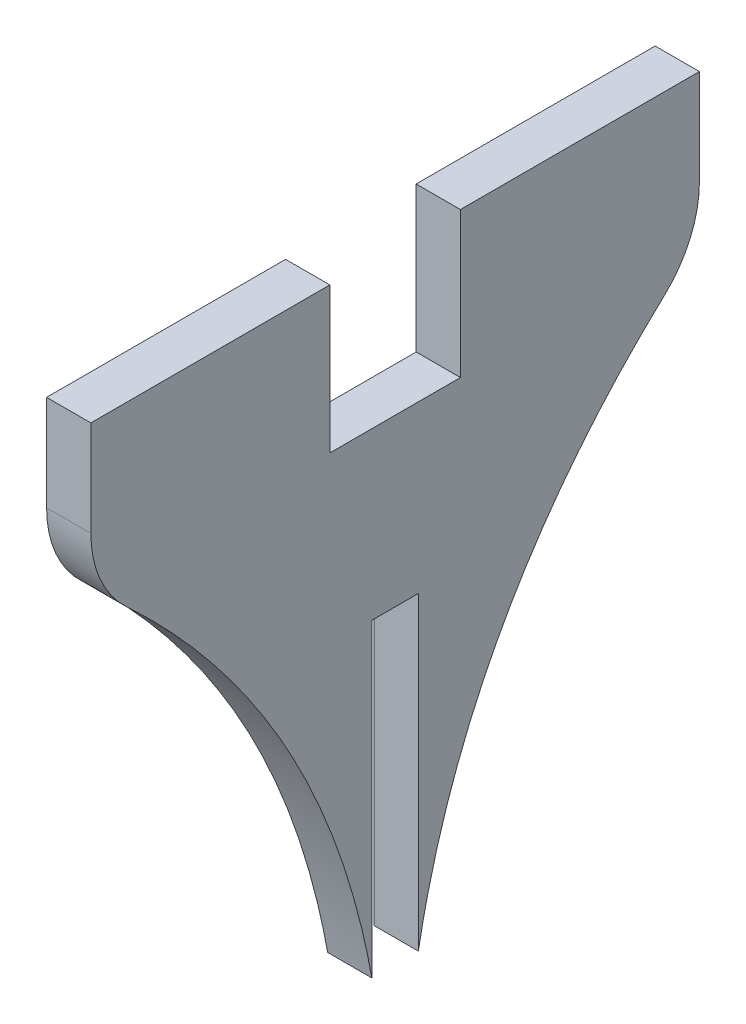
from build123d import *

# Parameters (mm, degrees)
BOSS_EXTRU_1_DEPTH = 4
CONG_1_R           = 10


with BuildPart() as part:
    # Esquisse1 → Boss.-Extru.1 (new body)
    with BuildSketch(Plane(origin=(0, 0, 0), x_dir=(0, 0, -1), z_dir=(1, 0, 0))):
        with BuildLine():
            Line((-27.5, 13.15), (-27.5, 0))
            add(Edge.make_bspline(
                [(-27.5, 0), (-6.736181912, -17.460350191), (-2.1, -43)],
                knots=[0, 0, 0, 1, 1, 1], degree=2))
            Line((-2.1, -43), (-2.1, -15))
            Line((-2.1, -15), (2.1, -15))
            Line((2.1, -15), (2.1, -43))
            add(Edge.make_bspline(
                [(27.5, 0), (6.736181912, -17.460350191), (2.1, -43)],
                knots=[0, 0, 0, 1, 1, 1], degree=2))
            Line((27.5, 0), (27.5, 13.15))
            Line((27.5, 13.15), (5.9, 13.15))
            Line((5.9, 13.15), (5.9, 0))
            Line((5.9, 0), (-5.9, 0))
            Line((-5.9, 0), (-5.9, 13.15))
            Line((-5.9, 13.15), (-27.5, 13.15))
        make_face()
    extrude(amount=BOSS_EXTRU_1_DEPTH)

    # Congé1
    cong_1_edges = [part.edges().sort_by_distance(p)[0] for p in [
        (2, 0, -27.5),
        (2, 0, 27.5),
    ]]
    fillet(cong_1_edges, radius=CONG_1_R)


solid = part.part
